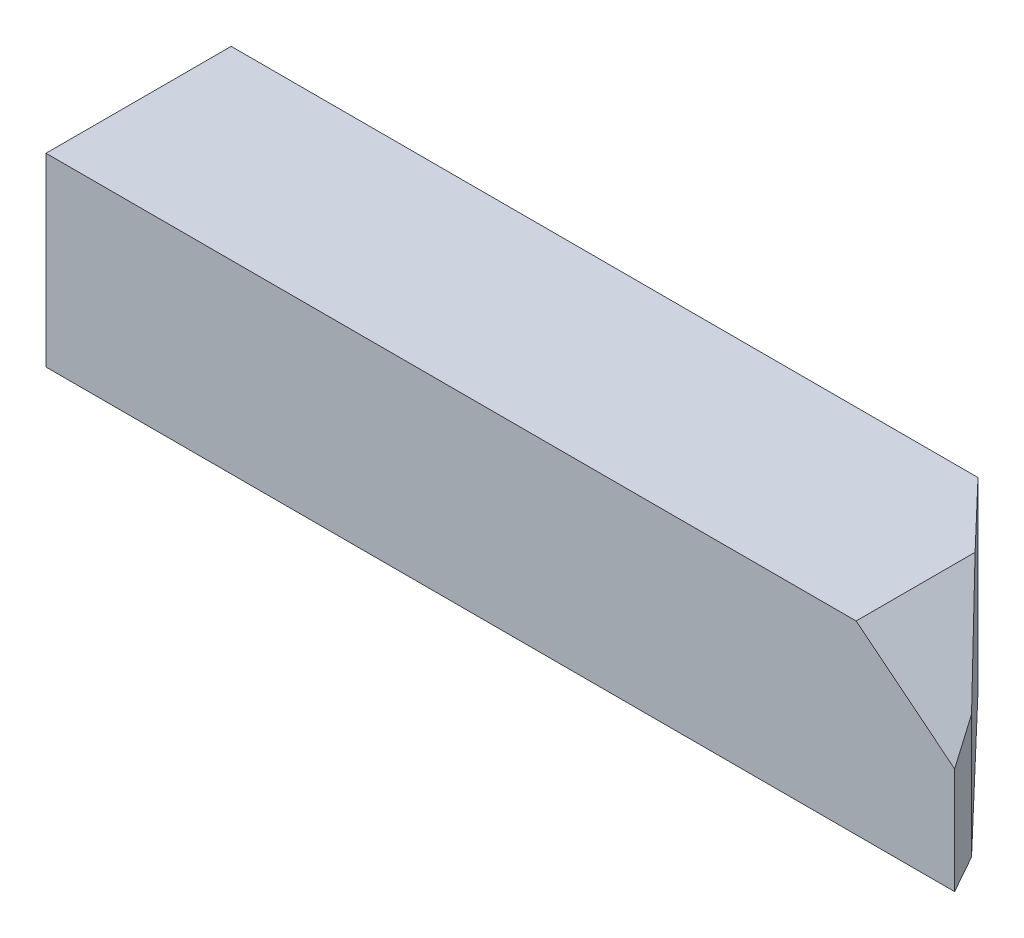
from build123d import *

# Parameters (mm, degrees)
EXTRUDE_1_DEPTH     = 8
CUT_EXTRUDE_1_DEPTH = 9


with BuildPart() as part:
    # Эскиз1 → Бобышка-Вытянуть1 (new body)
    with BuildSketch(Plane.XY):
        Polygon((0, 0), (0, 8), (35, 8), (39.256106995, 4.595114404), (39.256106995, 0), align=None)
    extrude(amount=EXTRUDE_1_DEPTH)

    # Эскиз2 → Вырез-Вытянуть1 (cut, through all)
    with BuildSketch(Plane.XZ):
        Polygon((32.26555928, 0), (39.256106995, 0), (39.256106995, 8), (38.325183504, 6.338802332), align=None)
    extrude(amount=-CUT_EXTRUDE_1_DEPTH, mode=Mode.SUBTRACT)


solid = part.part
